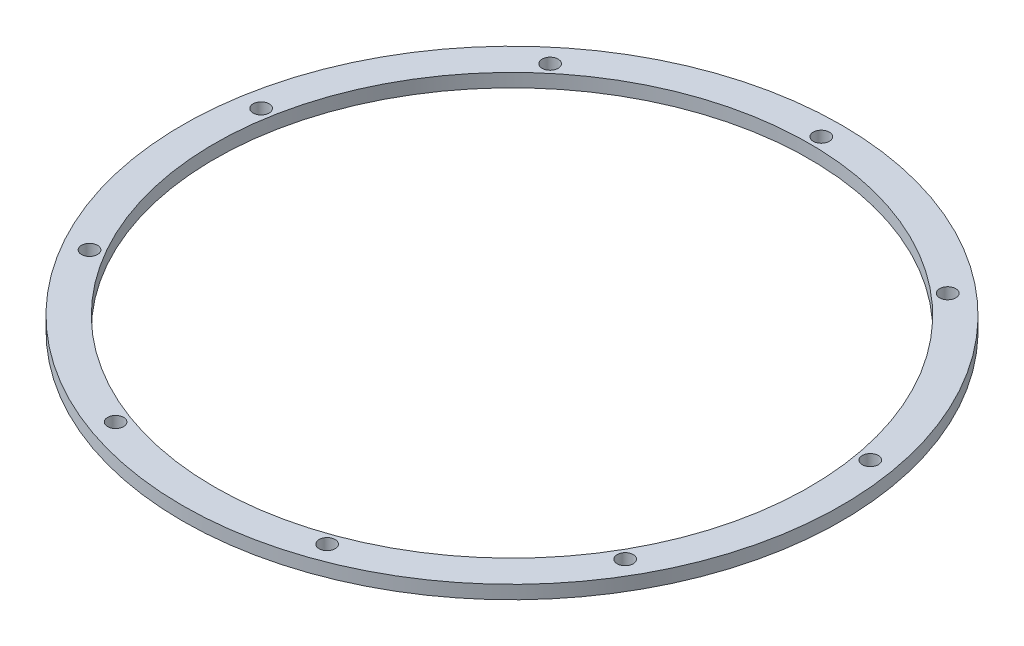
from build123d import *

# Parameters (mm, degrees)
ESQUISSE1_R        = 123.075
ESQUISSE1_R_2      = 111.1
ESQUISSE1_R_3      = 3
BOSS_EXTRU_1_DEPTH = 5


with BuildPart() as part:
    # Esquisse1 → Boss.-Extru.1 (new body)
    with BuildSketch(Plane(origin=(0, 0, 0), x_dir=(1, 0, 0), z_dir=(0, 1, 0))):
        with Locations(Location((0, 0, 0), (0, 0, 270))):  # turned: the seam where the file's is
            Circle(ESQUISSE1_R)
        with Locations(Location((0, 0, 0), (0, 0, 270))):  # turned: the seam where the file's is
            Circle(ESQUISSE1_R_2, mode=Mode.SUBTRACT)
        with Locations(Location((0, 115.5, 0), (0, 0, 270))):  # turned: the seam where the file's is
            Circle(ESQUISSE1_R_3, mode=Mode.SUBTRACT)
        with Locations(Location((74.241968919, 88.47813318, 0), (0, 0, 270))):  # turned: the seam where the file's is
            Circle(ESQUISSE1_R_3, mode=Mode.SUBTRACT)
        with Locations(Location((113.745295473, 20.056364521, 0), (0, 0, 270))):  # turned: the seam where the file's is
            Circle(ESQUISSE1_R_3, mode=Mode.SUBTRACT)
        with Locations(Location((100.025934137, -57.75, 0), (0, 0, 270))):  # turned: the seam where the file's is
            Circle(ESQUISSE1_R_3, mode=Mode.SUBTRACT)
        with Locations(Location((39.503326554, -108.534497701, 0), (0, 0, 270))):  # turned: the seam where the file's is
            Circle(ESQUISSE1_R_3, mode=Mode.SUBTRACT)
        with Locations(Location((-39.503326554, -108.534497701, 0), (0, 0, 270))):  # turned: the seam where the file's is
            Circle(ESQUISSE1_R_3, mode=Mode.SUBTRACT)
        with Locations(Location((-100.025934137, -57.75, 0), (0, 0, 270))):  # turned: the seam where the file's is
            Circle(ESQUISSE1_R_3, mode=Mode.SUBTRACT)
        with Locations(Location((-113.745295473, 20.056364521, 0), (0, 0, 270))):  # turned: the seam where the file's is
            Circle(ESQUISSE1_R_3, mode=Mode.SUBTRACT)
        with Locations(Location((-74.241968919, 88.47813318, 0), (0, 0, 270))):  # turned: the seam where the file's is
            Circle(ESQUISSE1_R_3, mode=Mode.SUBTRACT)
    extrude(amount=BOSS_EXTRU_1_DEPTH)


solid = part.part
